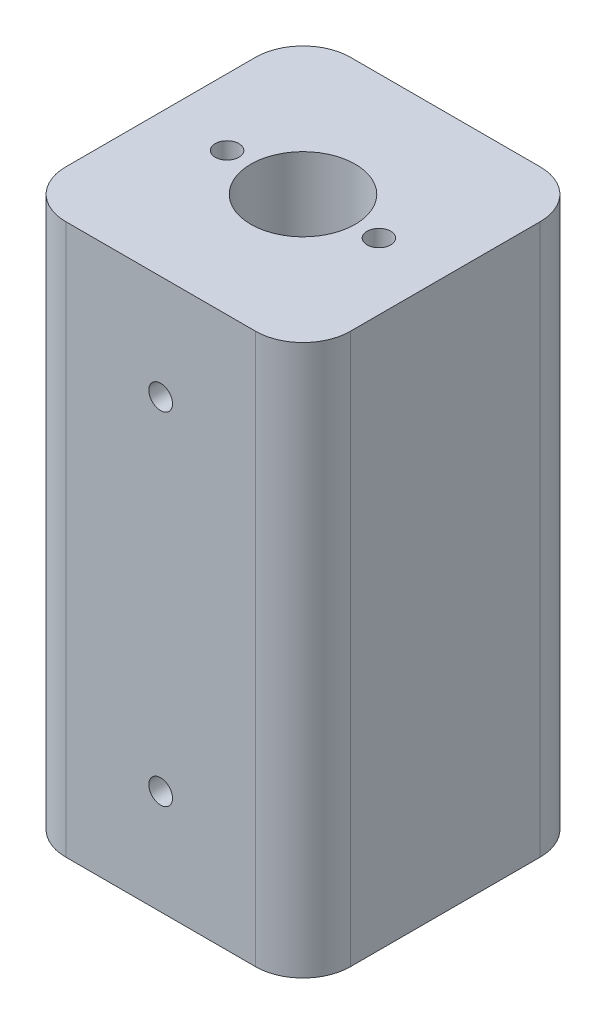
from build123d import *

# Parameters (mm, degrees)
SKETCH1_W           = 30
SKETCH1_H           = 30
BOSS_EXTRUDE1_DEPTH = 58
SKETCH2_R           = 5.5
SKETCH2_R_2         = 1.25
CUT_EXTRUDE1_DEPTH  = 10
SKETCH3_R           = 5.5
CUT_EXTRUDE2_DEPTH  = 49
SKETCH4_R           = 1.25
CUT_EXTRUDE3_DEPTH  = 8
FILLET1_R           = 5


with BuildPart() as part:
    # Sketch1 → Boss-Extrude1 (new body)
    with BuildSketch(Plane(origin=(0, 0, 0), x_dir=(1, 0, 0), z_dir=(0, 1, 0))):
        Rectangle(SKETCH1_W, SKETCH1_H)
    extrude(amount=BOSS_EXTRUDE1_DEPTH)

    # Sketch2 → Cut-Extrude1 (cut)
    with BuildSketch(Plane(origin=(0, 58, 0), x_dir=(1, 0, 0), z_dir=(0, 1, 0))):
        Circle(SKETCH2_R)
        with Locations((8, 0)):
            Circle(SKETCH2_R_2)
        with Locations((-8, 0)):
            Circle(SKETCH2_R_2)
    extrude(amount=-CUT_EXTRUDE1_DEPTH, mode=Mode.SUBTRACT)

    # Sketch3 → Cut-Extrude2 (cut, through all)
    with BuildSketch(Plane(origin=(0, 48, 0), x_dir=(1, 0, 0), z_dir=(0, 1, 0))):
        Circle(SKETCH3_R)
    extrude(amount=-CUT_EXTRUDE2_DEPTH, mode=Mode.SUBTRACT)

    # Sketch4 → Cut-Extrude3 (cut)
    with BuildSketch(Plane.XY.offset(15)):
        with Locations((0, 47)):
            Circle(SKETCH4_R)
        with Locations((0, 11)):
            Circle(SKETCH4_R)
    cut_extrude3 = extrude(amount=-CUT_EXTRUDE3_DEPTH, mode=Mode.SUBTRACT)

    # Mirror1: Cut-Extrude3 across plane
    add(cut_extrude3.mirror(Plane.XY), mode=Mode.SUBTRACT)

    # Fillet1
    fillet1_edges = [part.edges().sort_by_distance(p)[0] for p in [
        (15, 29, 15),
        (-15, 29, 15),
        (-15, 29, -15),
        (15, 29, -15),
    ]]
    fillet(fillet1_edges, radius=FILLET1_R)


solid = part.part
